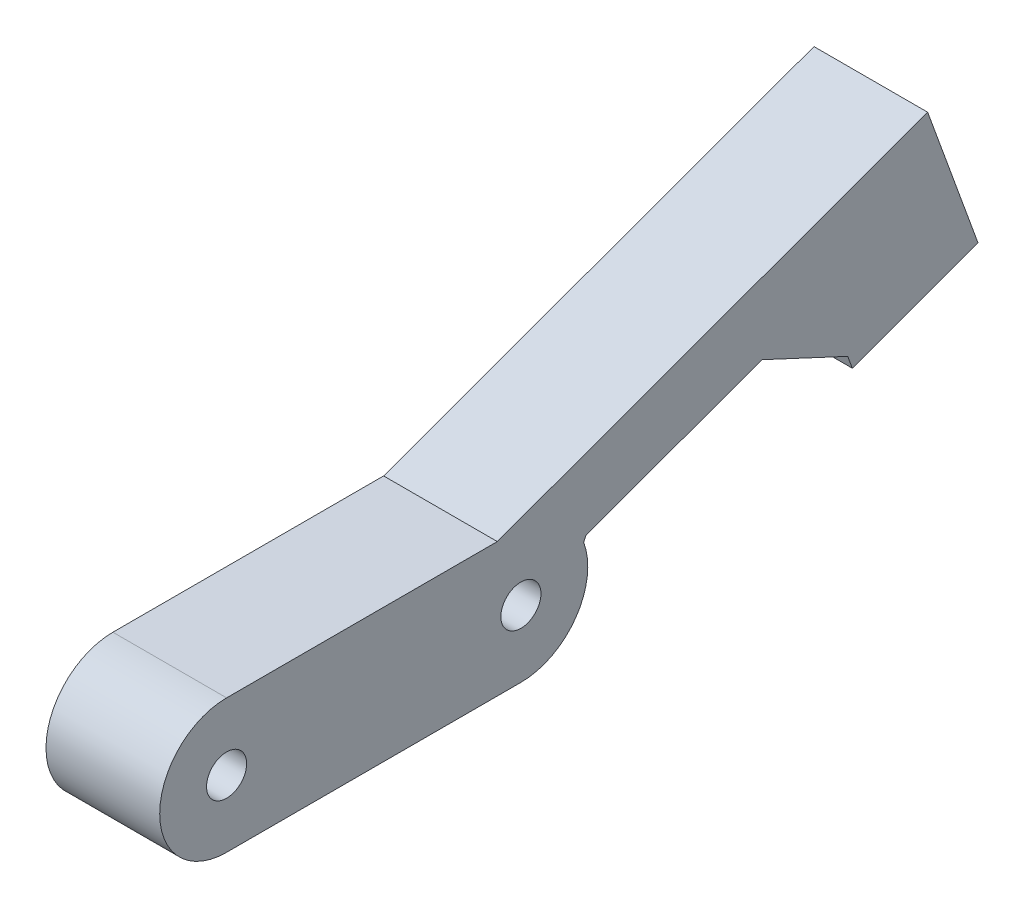
from build123d import *

# Parameters (mm, degrees)
SKETCH1_R           = 1.5
BOSS_EXTRUDE1_DEPTH = 8.5
BOSS_EXTRUDE2_DEPTH = 8.5


with BuildPart() as part:
    # Sketch1 → Boss-Extrude1 (new body)
    with BuildSketch(Plane(origin=(0, 0, 0), x_dir=(0, 0, -1), z_dir=(1, 0, 0))):
        with BuildLine():
            Line((27, 10), (5, 10))
            ThreePointArc((5, 10), (0, 5), (5, 0))
            Line((5, 0), (27, 0))
            ThreePointArc((27, 0), (32, 5), (27, 10))
        make_face()
        with Locations((5, 5)):
            Circle(SKETCH1_R, mode=Mode.SUBTRACT)
        with Locations((27, 5)):
            Circle(SKETCH1_R, mode=Mode.SUBTRACT)
    extrude(amount=BOSS_EXTRUDE1_DEPTH)

    # Sketch2 → Boss-Extrude2 (add)
    with BuildSketch(Plane(origin=(8.5, 0, 0), x_dir=(0, 0, -1), z_dir=(1, 0, 0))):
        with BuildLine():
            ThreePointArc((27, 10), (29.863119288, 9.099091112), (31.69447473, 6.721019177))
            Line((31.69447473, 6.721019177), (31.867747629, 7.092604107))
            Line((31.867747629, 7.092604107), (45.02344432, 11.880886114))
            Line((45.02344432, 11.880886114), (51.43200814, 8.892523726))
            Line((51.43200814, 8.892523726), (60.828934348, 12.31272516))
            Line((60.828934348, 12.31272516), (57.408732915, 21.709651368))
            Line((57.408732915, 21.709651368), (25.236730193, 10))
            Line((25.236730193, 10), (27, 10))
        make_face()
        Polygon((60.828934348, 12.31272516), (51.43200814, 8.892523726), (51.774028284, 7.952831106), (61.170954492, 11.373032539), align=None)
    extrude(amount=-BOSS_EXTRUDE2_DEPTH)


solid = part.part
